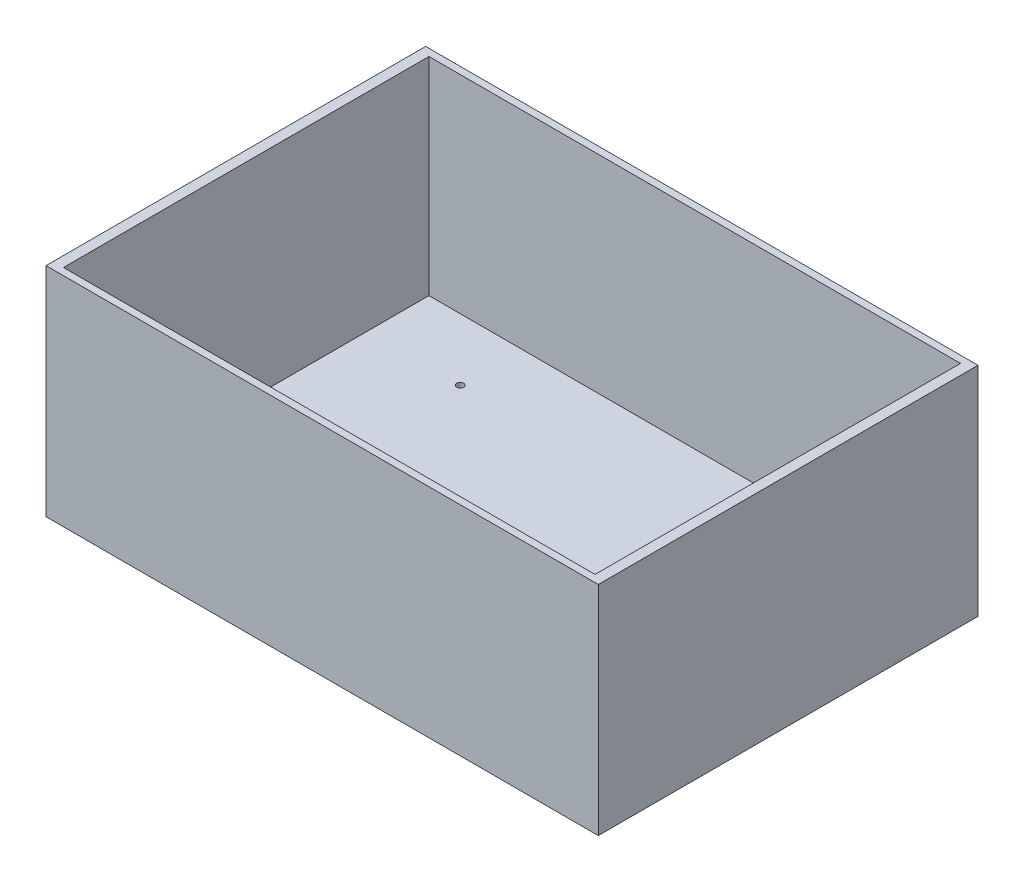
from build123d import *

# Parameters (mm, degrees)
SKETCH_1_W          = 160
SKETCH_1_H          = 110
EXTRUDE_1_DEPTH     = 3
SKETCH_2_W          = 160
SKETCH_2_H          = 110
SKETCH_2_W_2        = 154
SKETCH_2_H_2        = 105.875
EXTRUDE_2_DEPTH     = 60
SKETCH_3_R          = 1
CUT_EXTRUDE_1_DEPTH = 10


with BuildPart() as part:
    # 草图1 → 凸台-拉伸1 (new body)
    with BuildSketch(Plane(origin=(0, 0, 0), x_dir=(1, 0, 0), z_dir=(0, 1, 0))):
        Rectangle(SKETCH_1_W, SKETCH_1_H)
    extrude(amount=EXTRUDE_1_DEPTH)

    # 草图2 → 凸台-拉伸2 (add)
    with BuildSketch(Plane(origin=(0, 3, 0), x_dir=(1, 0, 0), z_dir=(0, 1, 0))):
        Rectangle(SKETCH_2_W, SKETCH_2_H)
        Rectangle(SKETCH_2_W_2, SKETCH_2_H_2, mode=Mode.SUBTRACT)
    extrude(amount=EXTRUDE_2_DEPTH)

    # 草图3 → 切除-拉伸1 (cut)
    with BuildSketch(Plane(origin=(0, 3, 0), x_dir=(1, 0, 0), z_dir=(0, 1, 0))):
        with Locations((-50, 35)):
            Circle(SKETCH_3_R)
        with Locations((50, 35)):
            Circle(SKETCH_3_R)
        with Locations((50, -35)):
            Circle(SKETCH_3_R)
        with Locations((-50, -35)):
            Circle(SKETCH_3_R)
    extrude(amount=-CUT_EXTRUDE_1_DEPTH, mode=Mode.SUBTRACT)


solid = part.part
